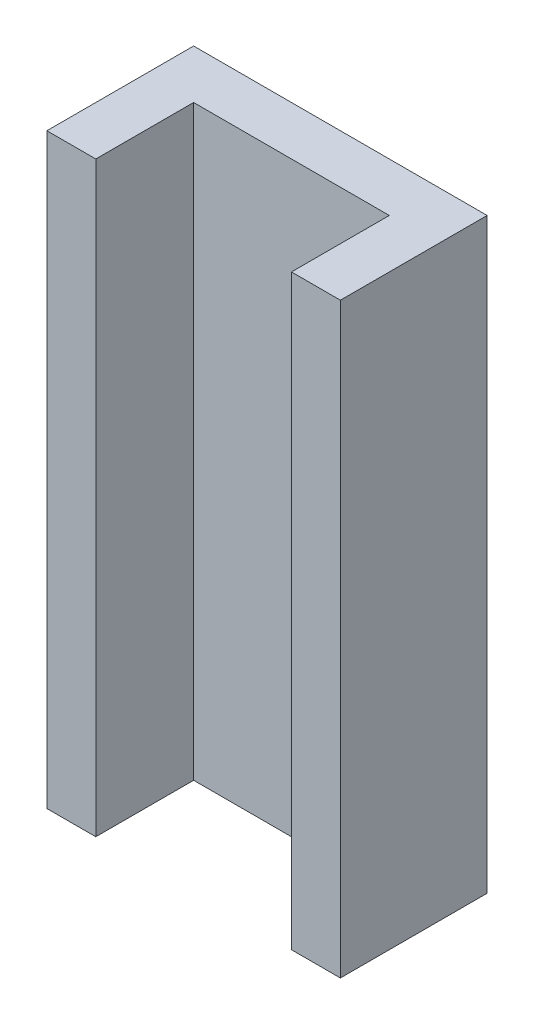
from build123d import *

# Parameters (mm, degrees)
BOSS_EXTRUDE1_DEPTH = 38.1


with BuildPart() as part:
    # Sketch3 → Boss-Extrude1 (new body, symmetric)
    with BuildSketch(Plane(origin=(0, 0, 0), x_dir=(1, 0, 0), z_dir=(0, 1, 0))):
        Polygon((19.05, 19.05), (-19.05, 19.05), (-19.05, 0), (-12.7, 0), (-12.7, 12.7), (12.7, 12.7), (12.7, 0), (19.05, 0), align=None)
    extrude(amount=BOSS_EXTRUDE1_DEPTH, both=True)


solid = part.part
